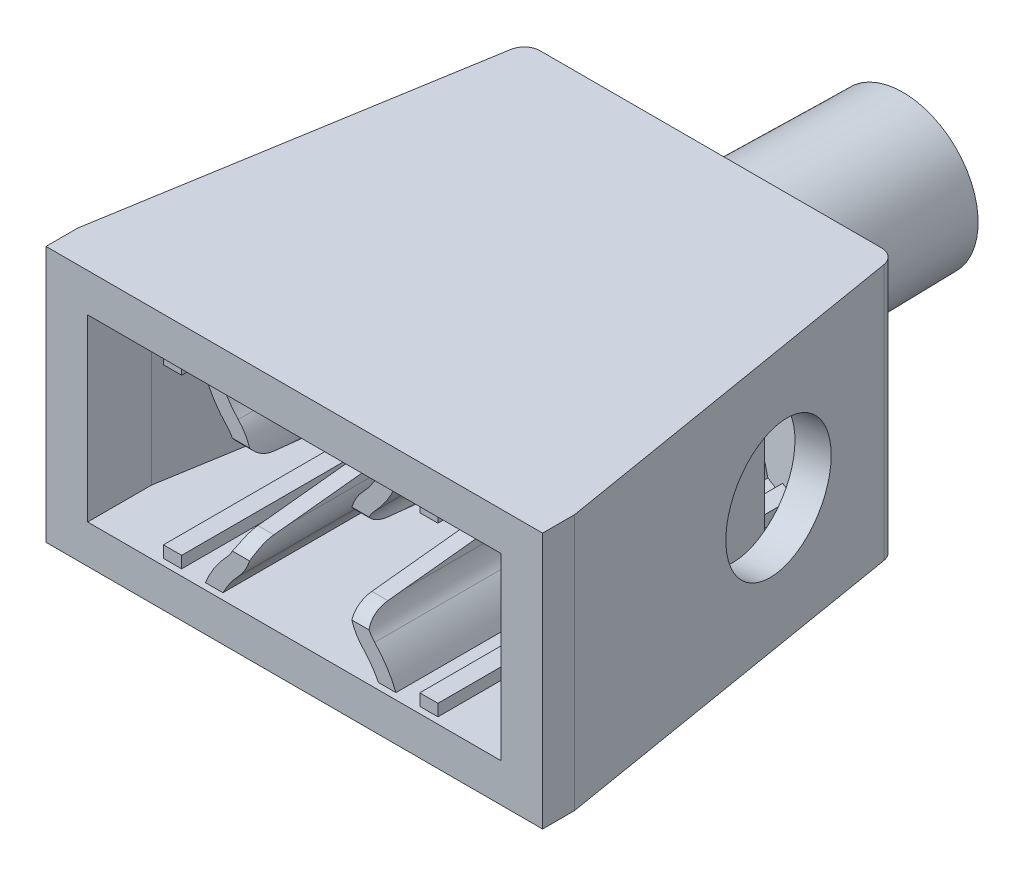
from build123d import *

# Parameters (mm, degrees)
BOSS_EXTRUDE1_DEPTH     = 8
FILLET1_R               = 0.5
SKETCH5_R               = 2.45
BOSS_EXTRUDE2_DEPTH     = 6
BOSS_EXTRUDE2_TAPER     = 1
CUT_EXTRUDE4_DEPTH      = 2.8
CUT_EXTRUDE4_DEPTH_BACK = 2.8
SKETCH10_R              = 1.45
CUT_EXTRUDE5_DEPTH      = 6
CUT_EXTRUDE5_TAPER      = 1
SKETCH7_R               = 2
CUT_EXTRUDE6_DEPTH      = 1
SKETCH8_R               = 2
CUT_EXTRUDE7_DEPTH      = 1
BOSS_EXTRUDE4_START     = -0.2
SKETCH11_W              = 0.564613496
SKETCH11_H              = 0.366319064
SKETCH11_W_2            = 0.56674541
SKETCH11_H_2            = 0.366442951
BOSS_EXTRUDE4_DEPTH     = 12.3
CUT_EXTRUDE8_DEPTH      = 3
CUT_EXTRUDE8_DEPTH_BACK = 2.5


with BuildPart() as part:
    # Sketch3 → Boss-Extrude1 (new body)
    with BuildSketch(Plane(origin=(0, 0, 0), x_dir=(1, 0, 0), z_dir=(0, 1, 0))):
        Polygon((7.75, 0), (-7.75, 0), (-7.75, 1), (-5.75, 13), (5.75, 13), (7.75, 1), align=None)
    extrude(amount=BOSS_EXTRUDE1_DEPTH)

    # Fillet1
    fillet1_edges = [part.edges().sort_by_distance(p)[0] for p in [
        (5.75, 4, -13),
        (-5.75, 4, -13),
    ]]
    fillet(fillet1_edges, radius=FILLET1_R)

    # Sketch5 → Boss-Extrude2 (add)
    with BuildSketch(Plane(origin=(0, 0, -13), x_dir=(-1, 0, 0), z_dir=(0, 0, -1))):
        with Locations((0, 4.19602759)):
            Circle(SKETCH5_R)
    extrude(amount=BOSS_EXTRUDE2_DEPTH, taper=BOSS_EXTRUDE2_TAPER)

    # Sketch9 → Cut-Extrude4 (cut, two sides)
    with BuildSketch(Plane(origin=(0, 4, 0), x_dir=(1, 0, 0), z_dir=(0, 1, 0))) as cut_extrude4_sk:
        Polygon((-6.45, 0), (-6.45, 2), (-4.95, 11), (-2.467455065, 12), (-1.480633364, 12), (1.480633364, 12), (2.467455065, 12), (5.096667593, 11), (6.45, 2), (6.45, 0), align=None)
    extrude(amount=CUT_EXTRUDE4_DEPTH, mode=Mode.SUBTRACT)
    extrude(cut_extrude4_sk.sketch, amount=-CUT_EXTRUDE4_DEPTH_BACK, mode=Mode.SUBTRACT)

    # Sketch10 → Cut-Extrude5 (cut)
    with BuildSketch(Plane.XY.offset(-12)):
        with Locations((0, 4)):
            Circle(SKETCH10_R)
    extrude(amount=-CUT_EXTRUDE5_DEPTH, taper=CUT_EXTRUDE5_TAPER, mode=Mode.SUBTRACT)

    # Sketch7 → Cut-Extrude6 (cut)
    with BuildSketch(Plane(origin=(7.702702703, 0, -1.283783784), x_dir=(-0.164398987, 0, -0.986393924), z_dir=(0.986393924, 0, -0.164398987))):
        with Locations((7.454263289, 4)):
            Circle(SKETCH7_R)
    extrude(amount=-CUT_EXTRUDE6_DEPTH, mode=Mode.SUBTRACT)

    # Sketch8 → Cut-Extrude7 (cut)
    with BuildSketch(Plane(origin=(-7.702702703, 0, -1.283783784), x_dir=(-0.164398987, 0, 0.986393924), z_dir=(-0.986393924, 0, -0.164398987))):
        with Locations((-7.454263289, 4)):
            Circle(SKETCH8_R)
    extrude(amount=-CUT_EXTRUDE7_DEPTH, mode=Mode.SUBTRACT)

    # Sketch11 → Boss-Extrude4 (add)
    with BuildSketch(Plane.XY.offset(BOSS_EXTRUDE4_START)):
        with BuildLine():
            Line((1.528607349, 5.080212301), (1.528607349, 4))
            Line((1.528607349, 4), (2.028607349, 4))
            Line((2.028607349, 4), (2.028607349, 5.080212301))
            ThreePointArc((2.028607349, 5.080212301), (2.101266499, 5.454430085), (2.308685248, 5.774267176))
            ThreePointArc((2.308685248, 5.774267176), (2.690610434, 6.255141934), (2.973871917, 6.8))
            Line((2.973871917, 6.8), (2.426326427, 6.8))
            ThreePointArc((2.426326427, 6.8), (2.213690864, 6.442234714), (1.948724198, 6.121294613))
            ThreePointArc((1.948724198, 6.121294613), (1.637596075, 5.641538977), (1.528607349, 5.080212301))
        make_face()
        with BuildLine():
            ThreePointArc((1.948724198, 1.878705387), (2.213690864, 1.557765286), (2.426326427, 1.2))
            Line((2.426326427, 1.2), (2.973871917, 1.2))
            ThreePointArc((2.973871917, 1.2), (2.690610434, 1.744858066), (2.308685248, 2.225732824))
            ThreePointArc((2.308685248, 2.225732824), (2.101266499, 2.545569915), (2.028607349, 2.919787699))
            Line((2.028607349, 2.919787699), (2.028607349, 4))
            Line((2.028607349, 4), (1.528607349, 4))
            Line((1.528607349, 4), (1.528607349, 2.919787699))
            ThreePointArc((1.528607349, 2.919787699), (1.637596075, 2.358461023), (1.948724198, 1.878705387))
        make_face()
        with Locations((4, 6.616840468)):
            Rectangle(SKETCH11_W, SKETCH11_H)
        with Locations((4, 1.383221476)):
            Rectangle(SKETCH11_W_2, SKETCH11_H_2)
    boss_extrude4 = extrude(amount=-BOSS_EXTRUDE4_DEPTH)

    # Mirror1: Boss-Extrude4 across plane
    add(boss_extrude4.mirror(Plane(origin=(0, 0, 0), x_dir=(0, 0, 1), z_dir=(1, 0, 0))))

    # Sketch12 → Cut-Extrude8 (cut, two sides)
    with BuildSketch(Plane(origin=(0, 0, 0), x_dir=(0, 0, -1), z_dir=(1, 0, 0))) as cut_extrude8_sk:
        with BuildLine():
            Line((0, 6.910389693), (0, 6.125652773))
            ThreePointArc((0, 6.125652773), (0.255989552, 5.45748479), (0.892896907, 5.131404852))
            Line((0.892896907, 5.131404852), (3.877195183, 4.809928115))
            ThreePointArc((3.877195183, 4.809928115), (4.60456136, 4), (3.877195183, 3.190071885))
            Line((3.877195183, 3.190071885), (0.892896907, 2.868595148))
            ThreePointArc((0.892896907, 2.868595148), (0.255989552, 2.54251521), (0, 1.874347227))
            Line((0, 1.874347227), (0, 1.089610307))
            Line((0, 1.089610307), (-0.964322492, 1.089610307))
            Line((-0.964322492, 1.089610307), (-0.964322492, 6.910389693))
            Line((-0.964322492, 6.910389693), (0, 6.910389693))
        make_face()
    extrude(amount=CUT_EXTRUDE8_DEPTH, mode=Mode.SUBTRACT)
    extrude(cut_extrude8_sk.sketch, amount=-CUT_EXTRUDE8_DEPTH_BACK, mode=Mode.SUBTRACT)


solid = part.part
